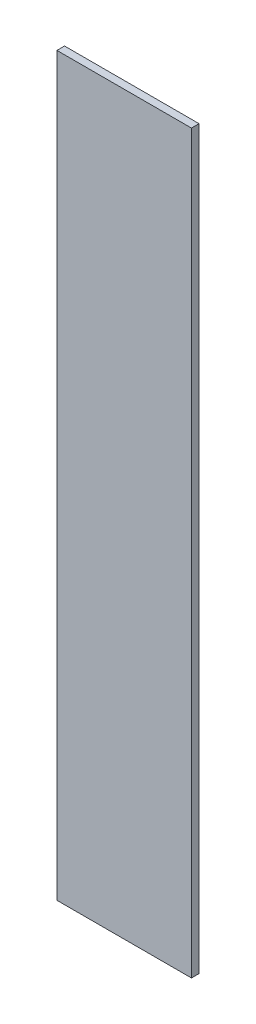
from build123d import *

# Parameters (mm, degrees)
ESQUISSE1_W        = 53
ESQUISSE1_H        = 290
BOSS_EXTRU_1_DEPTH = 3


with BuildPart() as part:
    # Esquisse1 → Boss.-Extru.1 (new body)
    with BuildSketch(Plane.XY):
        with Locations((-34.171773522, -113.774793388)):
            Rectangle(ESQUISSE1_W, ESQUISSE1_H)
    extrude(amount=BOSS_EXTRU_1_DEPTH)


solid = part.part
